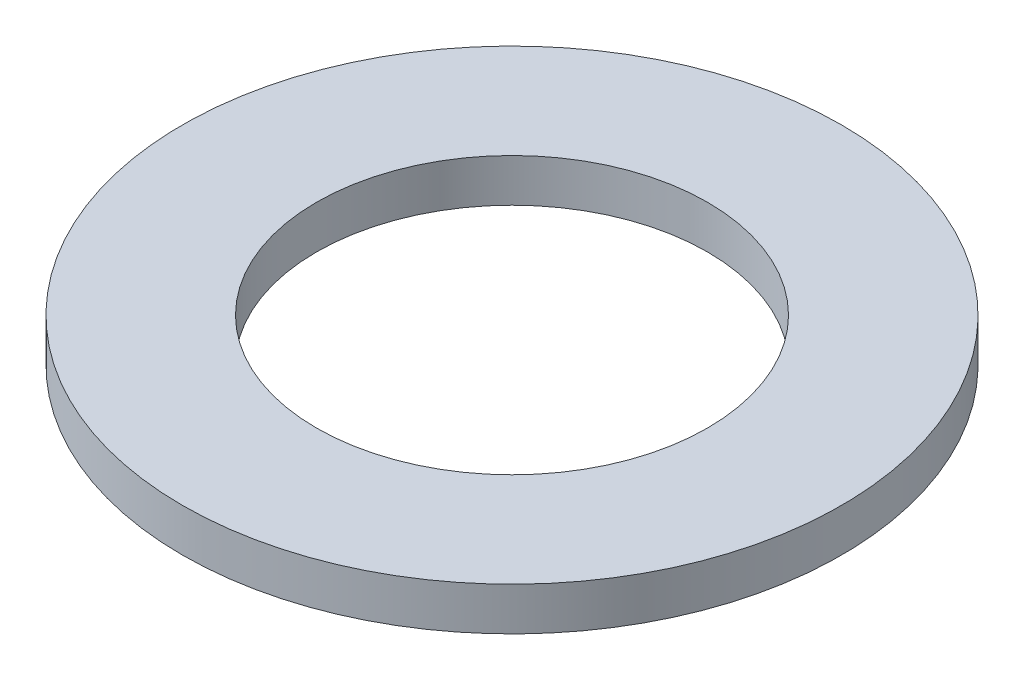
from build123d import *

# Parameters (mm, degrees)
SKETCH1_R           = 19.05
BOSS_EXTRUDE1_DEPTH = 2.4892
SKETCH5_R           = 11.303
CUT_EXTRUDE1_DEPTH  = 3.4892


with BuildPart() as part:
    # Sketch1 → Boss-Extrude1 (new body)
    with BuildSketch(Plane(origin=(0, 0, 0), x_dir=(1, 0, 0), z_dir=(0, 1, 0))):
        Circle(SKETCH1_R)
    extrude(amount=BOSS_EXTRUDE1_DEPTH)

    # Sketch5 → Cut-Extrude1 (cut, through all)
    with BuildSketch(Plane(origin=(0, 2.4892, 0), x_dir=(-1, 0, 0), z_dir=(0, 1, 0))):
        Circle(SKETCH5_R)
    extrude(amount=-CUT_EXTRUDE1_DEPTH, mode=Mode.SUBTRACT)


solid = part.part
